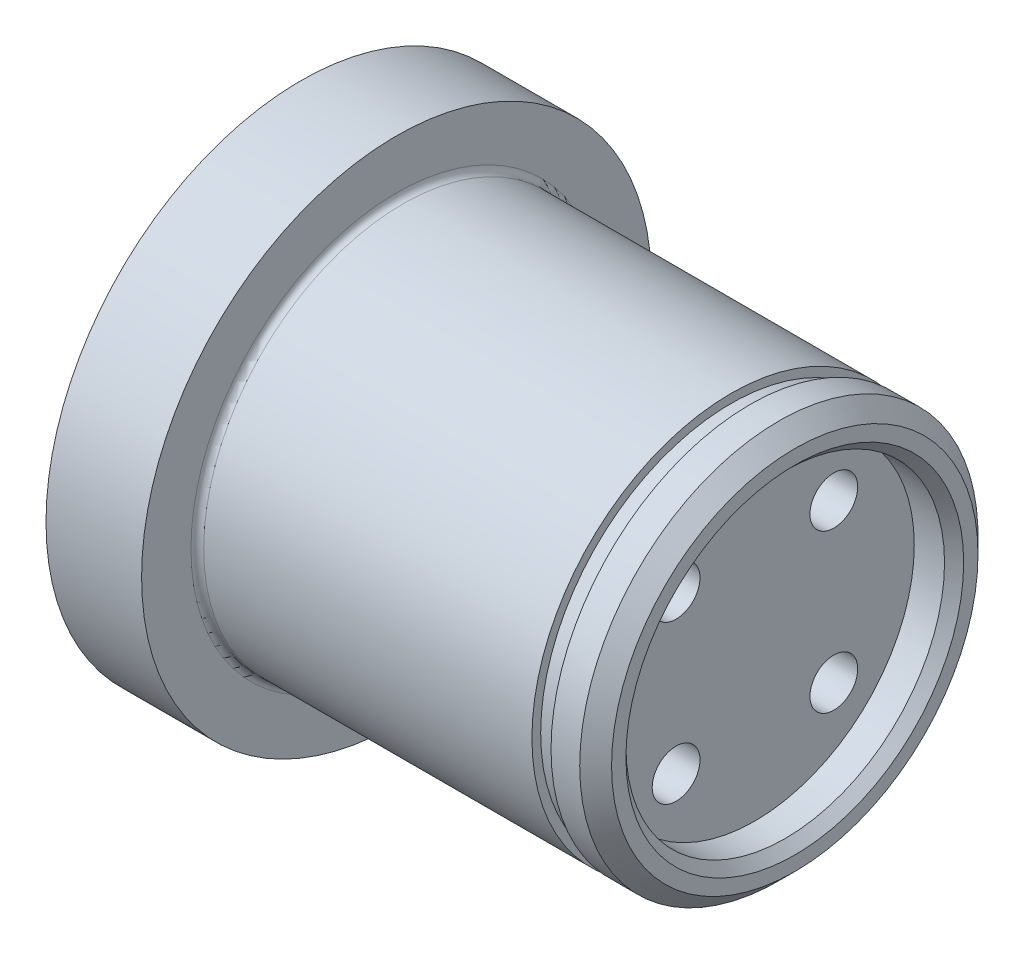
from build123d import *

# Parameters (mm, degrees)
SKETCH_2_W               = 1.2
SKETCH_2_H               = 0.55
CHAMFER_1_SIZE           = 1
FILLET_1_R               = 0.4
HOLE_WIZARD_1_D          = 3
HOLE_WIZARD_1_DEPTH      = 15
PATTERN_CIRCULAR_1_COUNT = 4
SKETCH_5_W               = 2.5
SKETCH_5_H               = 10
CHAMFER_2_SIZE           = 0.6
PATTERN_CIRCULAR_2_COUNT = 4


with BuildPart() as part:
    # Эскиз1 → Повернуть1 (revolve)
    with BuildSketch(Plane.XY):
        Polygon((0, 0), (0, 12.5), (-25, 12.5), (-25, 16), (-31, 16), (-31, 0), align=None)
    revolve(axis=Axis((0, 0, 0), (1, 0, 0)))

    # Эскиз2 → Вырез-Повернуть1 (revolve, cut)
    with BuildSketch(Plane.XY):
        with Locations((-3.4, 12.225)):
            Rectangle(SKETCH_2_W, SKETCH_2_H)
    revolve(axis=Axis((0, 0, 0), (-1, 0, 0)), mode=Mode.SUBTRACT)

    # Фаска1
    chamfer_1_edges = [part.edges().sort_by_distance(p)[0] for p in [
        (0, -12.5, 0),
    ]]
    chamfer(chamfer_1_edges, length=CHAMFER_1_SIZE)

    # Скругление1
    fillet_1_edges = [part.edges().sort_by_distance(p)[0] for p in [
        (-25, -12.5, 0),
    ]]
    fillet(fillet_1_edges, radius=FILLET_1_R)

    # Отверстие1
    with Locations(Plane(origin=(0, 0, 0), x_dir=(0, 0, -1), z_dir=(1, 0, 0))):
        with Locations((4.949747468, 4.949747468)):
            hole_wizard_1 = Hole(HOLE_WIZARD_1_D / 2, depth=HOLE_WIZARD_1_DEPTH)

    # Круговой массив1: Отверстие1 ×4 about axis
    pattern_circular_1_axis = Axis((0, 0, 0), (1, 0, 0))
    for i in range(1, PATTERN_CIRCULAR_1_COUNT):
        add(hole_wizard_1.rotate(pattern_circular_1_axis, i * 360 / PATTERN_CIRCULAR_1_COUNT), mode=Mode.SUBTRACT)

    # Эскиз5 → Вырез-Повернуть2 (revolve, cut)
    with BuildSketch(Plane.XY):
        with Locations((-1.25, 5)):
            Rectangle(SKETCH_5_W, SKETCH_5_H)
    revolve(axis=Axis((0, 0, 0), (-1, 0, 0)), mode=Mode.SUBTRACT)

    # Фаска2
    chamfer_2_edges = [part.edges().sort_by_distance(p)[0] for p in [
        (0, -10, 0),
    ]]
    chamfer(chamfer_2_edges, length=CHAMFER_2_SIZE)

    # Эскиз7 → Сверло под метчик  спиральное M31 (revolve, cut)
    with BuildSketch(Plane(origin=(-31, 0, -10), x_dir=(0, 0, 1), z_dir=(0, 1, 0))):
        Polygon((0, 0), (0, 20.946355475), (1.575, 20), (1.575, 0), align=None)
    hole_wizard_m31 = revolve(axis=Axis((-37.35, 0, -10), (1, 0, 0)), mode=Mode.SUBTRACT)

    # Круговой массив2: Сверло под метчик  спиральное M31 ×4 about axis
    pattern_circular_2_axis = Axis((0, 0, 0), (1, 0, 0))
    for i in range(1, PATTERN_CIRCULAR_2_COUNT):
        add(hole_wizard_m31.rotate(pattern_circular_2_axis, i * 360 / PATTERN_CIRCULAR_2_COUNT), mode=Mode.SUBTRACT)


solid = part.part
